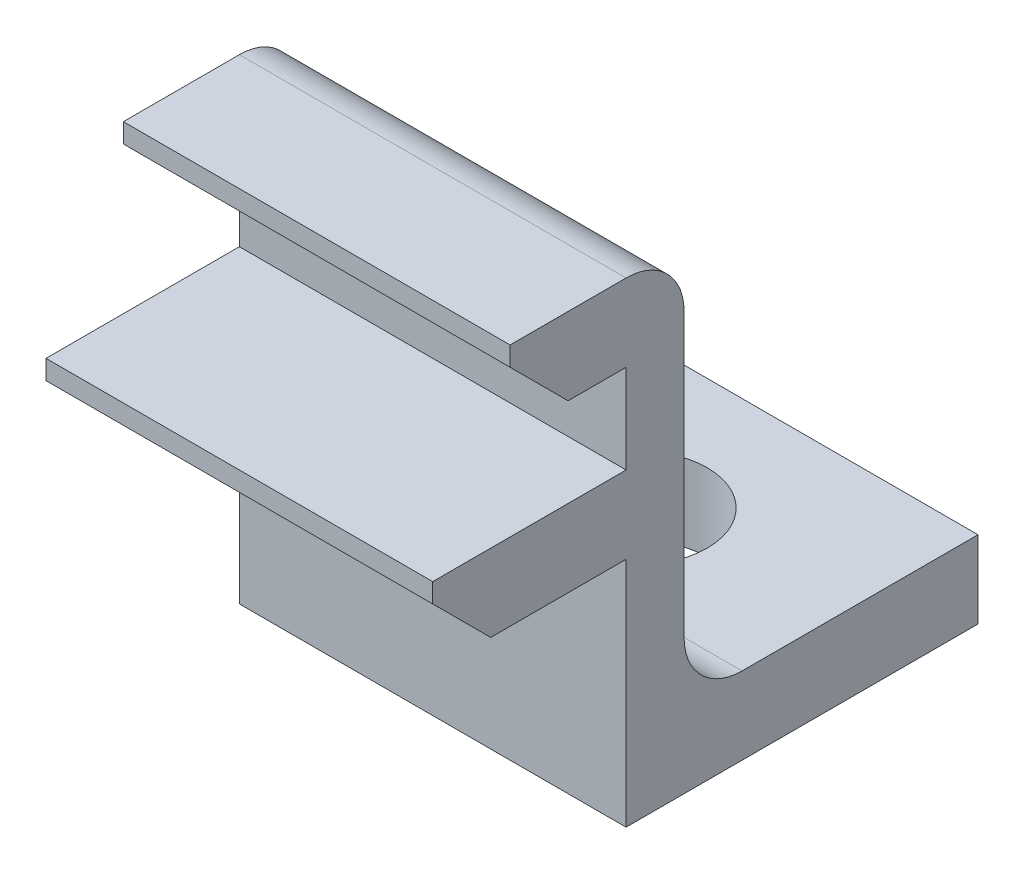
from build123d import *

# Parameters (mm, degrees)
BOSS_EXTRUDE1_DEPTH     = 5
CUT_EXTRUDE1_DEPTH      = 13.60684338
CUT_EXTRUDE1_DEPTH_BACK = 13.60684338
SKETCH2_R               = 1.8
CHAMFER2_SIZE           = 1.5
FILLET1_R               = 1.5


with BuildPart() as part:
    # Sketch1 → Boss-Extrude1 (new, symmetric)
    with BuildSketch(Plane(origin=(0, 0, 0), x_dir=(0, 0, -1), z_dir=(1, 0, 0))):
        Polygon((-3.8, 5.15), (-8.3, 5.15), (-8.3, 3.15), (-5.3, 3.15), (-5.3, 0.85), (-10.3, 0.85), (-10.3, -1.15), (-5.3, -1.15), (-5.3, -7.15), (3.8, -7.15), (3.8, -5.15), (-3.8, -5.15), align=None)
    extrude(amount=BOSS_EXTRUDE1_DEPTH, both=True)

    # Sketch2 → Cut-Extrude1 (cut, two sides: drawn at the far end of the back side and taken through both)
    with BuildSketch(Plane(origin=(0, 0, 5.3), x_dir=(1, 0, 0), z_dir=(0, -1, 0)).offset(-CUT_EXTRUDE1_DEPTH_BACK)):
        with Locations((0, -5.3)):
            Circle(SKETCH2_R)
    extrude(amount=CUT_EXTRUDE1_DEPTH + CUT_EXTRUDE1_DEPTH_BACK, mode=Mode.SUBTRACT)

    # Chamfer2
    chamfer2_edges = [part.edges().sort_by_distance(p)[0] for p in [
        (0, -1.15, 10.3),
        (0, 3.15, 8.3),
    ]]
    chamfer(chamfer2_edges, length=CHAMFER2_SIZE)

    # Fillet1
    fillet1_edges = [part.edges().sort_by_distance(p)[0] for p in [
        (0, -5.15, 3.8),
        (0, 5.15, 3.8),
    ]]
    fillet(fillet1_edges, radius=FILLET1_R)


solid = part.part
